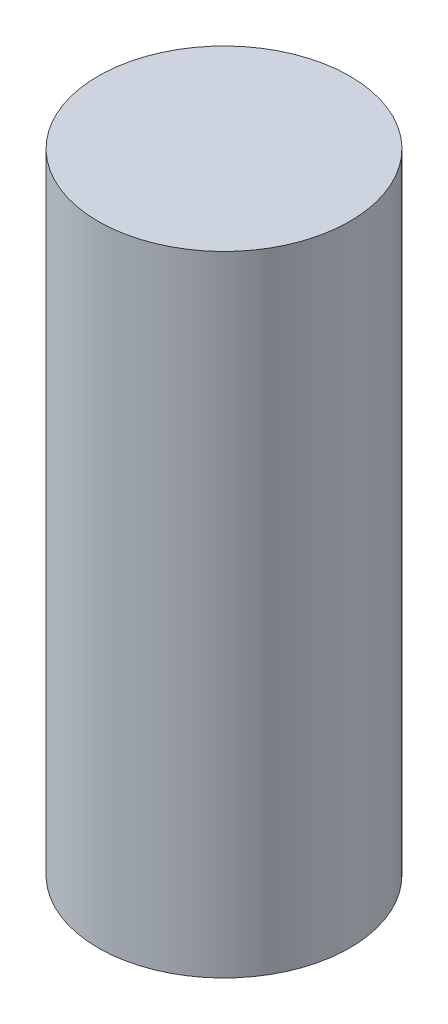
from build123d import *

# Parameters (mm, degrees)
SKETCH1_R           = 5
BOSS_EXTRUDE1_DEPTH = 25


with BuildPart() as part:
    # Sketch1 → Boss-Extrude1 (new body)
    with BuildSketch(Plane(origin=(0, 0, 0), x_dir=(1, 0, 0), z_dir=(0, 1, 0))):
        Circle(SKETCH1_R)
    extrude(amount=BOSS_EXTRUDE1_DEPTH)


solid = part.part
